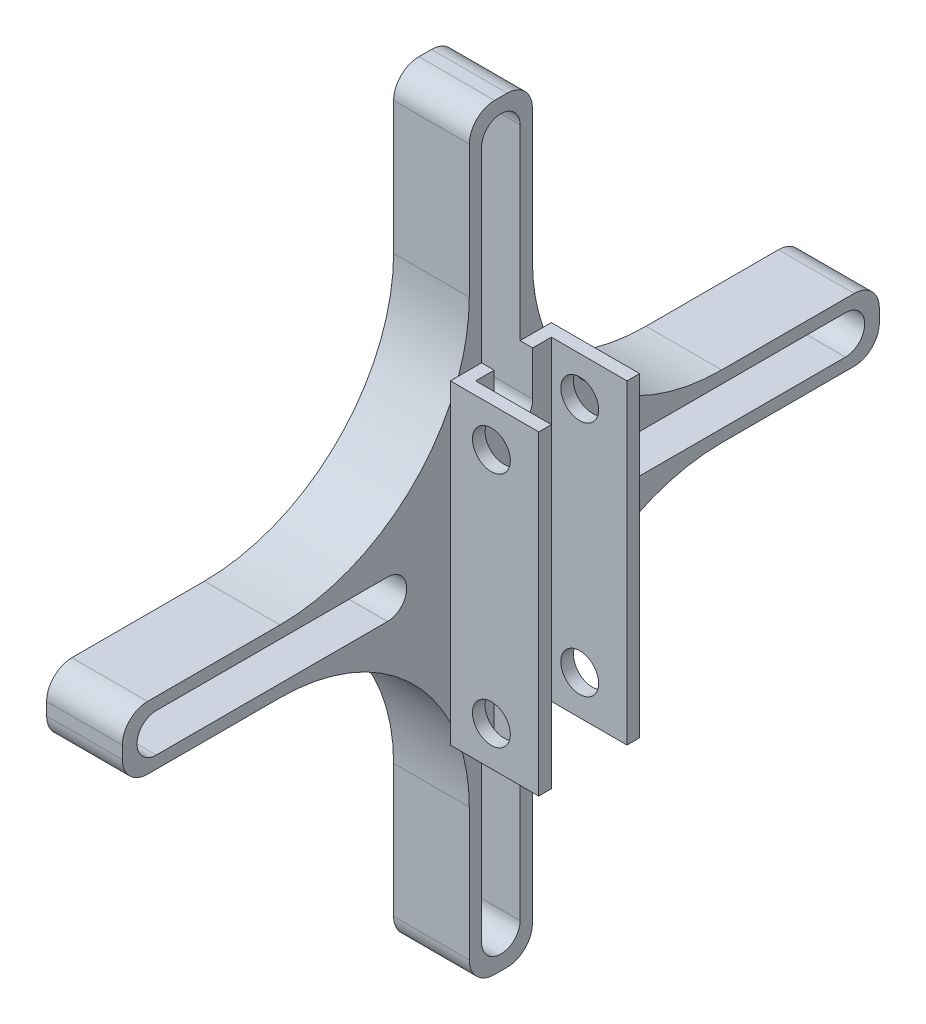
from build123d import *

# Parameters (mm, degrees)
BOSS_EXTRUDE1_DEPTH = 25
SKETCH2_R           = 1.5
CUT_EXTRUDE1_DEPTH  = 100
BOSS_EXTRUDE2_DEPTH = 6
CUT_EXTRUDE2_START  = -6
CUT_EXTRUDE2_DEPTH  = 6
CUT_EXTRUDE3_START  = -6
CUT_EXTRUDE3_DEPTH  = 6
SKETCH6_R           = 2
CUT_EXTRUDE4_DEPTH  = 60


with BuildPart() as part:
    # Sketch1 → Boss-Extrude1 (new body)
    with BuildSketch(Plane(origin=(0, 0, 0), x_dir=(1, 0, 0), z_dir=(0, 1, 0))):
        Polygon((-3, 3), (3, 3), (3, 4), (-4, 4), (-4, -4), (3, -4), (3, -3), (-3, -3), align=None)
    extrude(amount=BOSS_EXTRUDE1_DEPTH)

    # Sketch2 → Cut-Extrude1 (cut)
    with BuildSketch(Plane.XY.offset(4)):
        with Locations((-0.75, 3.105)):
            Circle(SKETCH2_R)
        with Locations((-0.75, 21.895)):
            Circle(SKETCH2_R)
    extrude(amount=-CUT_EXTRUDE1_DEPTH, mode=Mode.SUBTRACT)

    # Sketch3 → Boss-Extrude2 (add)
    with BuildSketch(Plane.ZY.offset(4)):
        with BuildLine():
            Line((0.5, 42.5), (-0.5, 42.5))
            ThreePointArc((-0.5, 42.5), (-1.914213562, 41.914213562), (-2.5, 40.5))
            Line((-2.5, 40.5), (-2.5, 30))
            ThreePointArc((-2.5, 30), (-6.893398282, 19.393398282), (-17.5, 15))
            Line((-17.5, 15), (-28, 15))
            ThreePointArc((-28, 15), (-29.414213562, 14.414213562), (-30, 13))
            Line((-30, 13), (-30, 12))
            ThreePointArc((-30, 12), (-29.414213562, 10.585786438), (-28, 10))
            Line((-28, 10), (-17.5, 10))
            ThreePointArc((-17.5, 10), (-6.893398282, 5.606601718), (-2.5, -5))
            Line((-2.5, -5), (-2.5, -15.5))
            ThreePointArc((-2.5, -15.5), (-1.914213562, -16.914213562), (-0.5, -17.5))
            Line((-0.5, -17.5), (0.5, -17.5))
            ThreePointArc((0.5, -17.5), (1.914213562, -16.914213562), (2.5, -15.5))
            Line((2.5, -15.5), (2.5, -5))
            ThreePointArc((2.5, -5), (6.893398282, 5.606601718), (17.5, 10))
            Line((17.5, 10), (28, 10))
            ThreePointArc((28, 10), (29.414213562, 10.585786438), (30, 12))
            Line((30, 12), (30, 13))
            ThreePointArc((30, 13), (29.414213562, 14.414213562), (28, 15))
            Line((28, 15), (17.5, 15))
            ThreePointArc((17.5, 15), (6.893398282, 19.393398282), (2.5, 30))
            Line((2.5, 30), (2.5, 40.5))
            ThreePointArc((2.5, 40.5), (1.914213562, 41.914213562), (0.5, 42.5))
        make_face()
        with BuildLine():
            Line((1.525, 39.812785606), (1.525, 21.487997416))
            ThreePointArc((1.525, 21.487997416), (0, 19.962997416), (-1.525, 21.487997416))
            Line((-1.525, 21.487997416), (-1.525, 39.812785606))
            ThreePointArc((-1.525, 39.812785606), (0, 41.337785606), (1.525, 39.812785606))
        make_face(mode=Mode.SUBTRACT)
        with BuildLine():
            Line((1.525, 3.512002584), (1.525, -14.812785606))
            ThreePointArc((1.525, -14.812785606), (0, -16.337785606), (-1.525, -14.812785606))
            Line((-1.525, -14.812785606), (-1.525, 3.512002584))
            ThreePointArc((-1.525, 3.512002584), (0, 5.037002584), (1.525, 3.512002584))
        make_face(mode=Mode.SUBTRACT)
        with BuildLine():
            ThreePointArc((27.312785606, 14.025), (28.837785606, 12.5), (27.312785606, 10.975))
            Line((27.312785606, 10.975), (8.987997416, 10.975))
            ThreePointArc((8.987997416, 10.975), (7.462997416, 12.5), (8.987997416, 14.025))
            Line((8.987997416, 14.025), (27.312785606, 14.025))
        make_face(mode=Mode.SUBTRACT)
        with BuildLine():
            Line((-27.312785606, 14.025), (-8.987997416, 14.025))
            ThreePointArc((-8.987997416, 14.025), (-7.462997416, 12.5), (-8.987997416, 10.975))
            Line((-8.987997416, 10.975), (-27.312785606, 10.975))
            ThreePointArc((-27.312785606, 10.975), (-28.837785606, 12.5), (-27.312785606, 14.025))
        make_face(mode=Mode.SUBTRACT)
    extrude(amount=BOSS_EXTRUDE2_DEPTH)

    # Sketch3_4 → Cut-Extrude2 (cut)
    with BuildSketch(Plane.ZY.offset(4).offset(CUT_EXTRUDE2_START)):
        with BuildLine():
            Line((-1.525, -14.812785606), (-1.525, 3.512002584))
            ThreePointArc((-1.525, 3.512002584), (0, 5.037002584), (1.525, 3.512002584))
            Line((1.525, 3.512002584), (1.525, -14.812785606))
            ThreePointArc((1.525, -14.812785606), (0, -16.337785606), (-1.525, -14.812785606))
        make_face()
    extrude(amount=CUT_EXTRUDE2_DEPTH, mode=Mode.SUBTRACT)

    # Sketch3_5 → Cut-Extrude3 (cut)
    with BuildSketch(Plane.ZY.offset(4).offset(CUT_EXTRUDE3_START)):
        with BuildLine():
            Line((-1.525, 39.812785606), (-1.525, 21.487997416))
            ThreePointArc((-1.525, 21.487997416), (0, 19.962997416), (1.525, 21.487997416))
            Line((1.525, 21.487997416), (1.525, 39.812785606))
            ThreePointArc((1.525, 39.812785606), (0, 41.337785606), (-1.525, 39.812785606))
        make_face()
    extrude(amount=CUT_EXTRUDE3_DEPTH, mode=Mode.SUBTRACT)

    # Sketch6 → Cut-Extrude4 (cut)
    with BuildSketch(Plane.ZY.offset(10)):
        with Locations((0, 12.5)):
            Circle(SKETCH6_R)
    extrude(amount=-CUT_EXTRUDE4_DEPTH, mode=Mode.SUBTRACT)


solid = part.part
